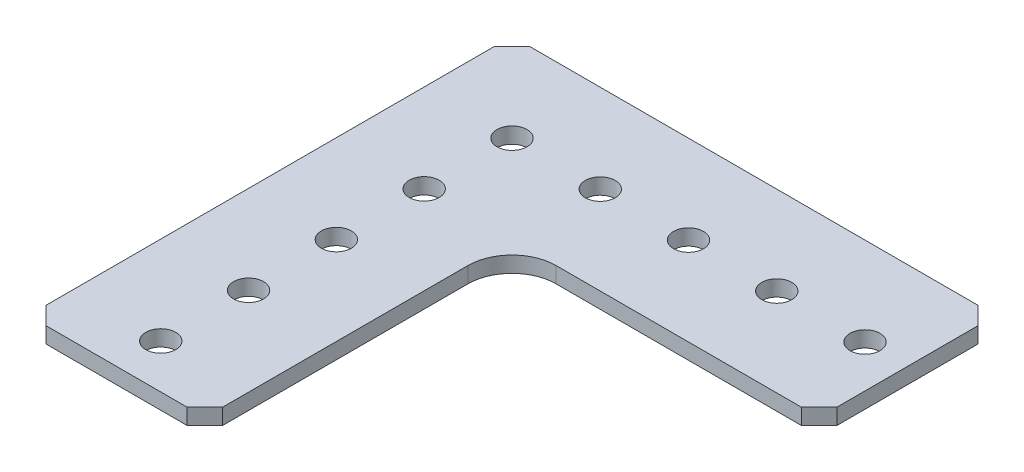
from build123d import *

# Parameters (mm, degrees)
SKETCH2_R           = 2.159
BOSS_EXTRUDE2_DEPTH = 2.286


with BuildPart() as part:
    # Sketch2 → Boss-Extrude2 (new body)
    with BuildSketch(Plane(origin=(0, 0, 0), x_dir=(1, 0, 0), z_dir=(0, 1, 0))):
        with BuildLine():
            Line((-39.486864346, -27.37374707), (-39.486864346, 37.14225293))
            Line((-39.486864346, 37.14225293), (-36.946864346, 39.68225293))
            Line((-36.946864346, 39.68225293), (27.569135654, 39.68225293))
            Line((27.569135654, 39.68225293), (30.109135654, 37.14225293))
            Line((30.109135654, 37.14225293), (30.109135654, 16.82225293))
            Line((30.109135654, 16.82225293), (27.569135654, 14.28225293))
            Line((27.569135654, 14.28225293), (-7.736864346, 14.28225293))
            ThreePointArc((-7.736864346, 14.28225293), (-12.226992406, 12.422380991), (-14.086864346, 7.93225293))
            Line((-14.086864346, 7.93225293), (-14.086864346, -27.37374707))
            Line((-14.086864346, -27.37374707), (-16.626864346, -29.91374707))
            Line((-16.626864346, -29.91374707), (-36.946864346, -29.91374707))
            Line((-36.946864346, -29.91374707), (-39.486864346, -27.37374707))
        make_face()
        with Locations((-26.786864346, 26.98225293)):
            Circle(SKETCH2_R, mode=Mode.SUBTRACT)
        with Locations((-14.086864346, 26.98225293)):
            Circle(SKETCH2_R, mode=Mode.SUBTRACT)
        with Locations((-1.386864346, 26.98225293)):
            Circle(SKETCH2_R, mode=Mode.SUBTRACT)
        with Locations((11.313135654, 26.98225293)):
            Circle(SKETCH2_R, mode=Mode.SUBTRACT)
        with Locations((24.013135654, 26.98225293)):
            Circle(SKETCH2_R, mode=Mode.SUBTRACT)
        with Locations((-26.786864346, 14.34575293)):
            Circle(SKETCH2_R, mode=Mode.SUBTRACT)
        with Locations((-26.786864346, 1.70925293)):
            Circle(SKETCH2_R, mode=Mode.SUBTRACT)
        with Locations((-26.786864346, -10.92724707)):
            Circle(SKETCH2_R, mode=Mode.SUBTRACT)
        with Locations((-26.786864346, -23.56374707)):
            Circle(SKETCH2_R, mode=Mode.SUBTRACT)
    extrude(amount=BOSS_EXTRUDE2_DEPTH)


solid = part.part
